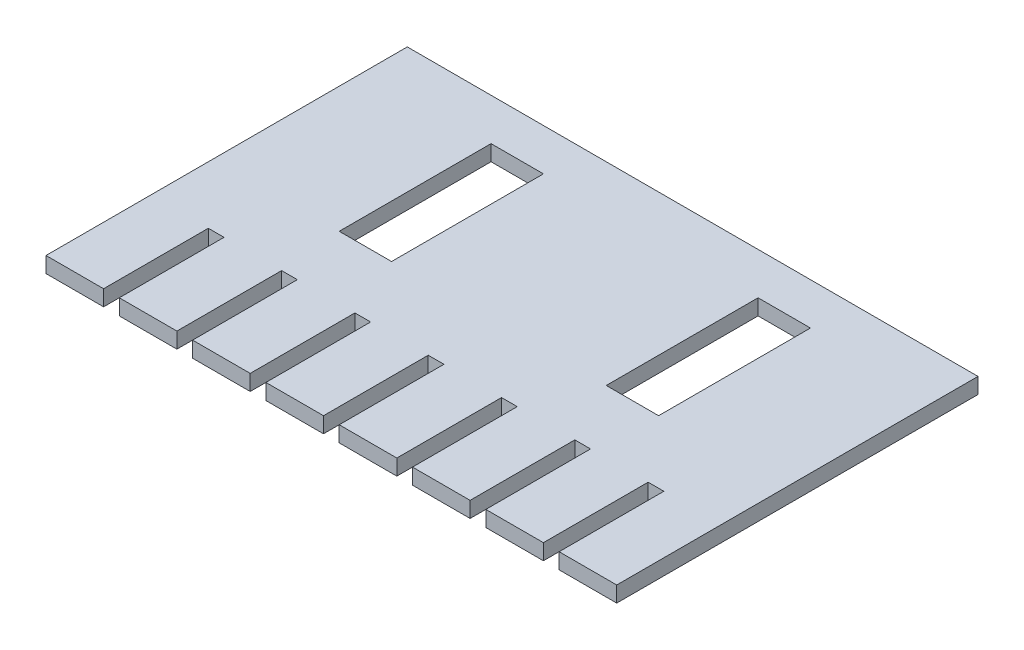
from build123d import *

# Parameters (mm, degrees)
SKETCH1_W           = 54.5
SKETCH1_H           = 34.5
BOSS_EXTRUDE1_DEPTH = 1.5
SKETCH6_W           = 5
SKETCH6_H           = 14.5
CUT_EXTRUDE1_DEPTH  = 2
SKETCH9_W           = 5
SKETCH9_H           = 14.5
CUT_EXTRUDE2_DEPTH  = 2
SKETCH27_W          = 1.5
SKETCH27_H          = 10
CUT_EXTRUDE3_DEPTH  = 2
SKETCH28_W          = 1.5
SKETCH28_H          = 10
CUT_EXTRUDE4_DEPTH  = 2
SKETCH29_W          = 1.5
SKETCH29_H          = 10
CUT_EXTRUDE5_DEPTH  = 2
SKETCH30_W          = 1.5
SKETCH30_H          = 10
CUT_EXTRUDE6_DEPTH  = 2
SKETCH31_W          = 1.5
SKETCH31_H          = 10
CUT_EXTRUDE7_DEPTH  = 2
SKETCH32_W          = 1.5
SKETCH32_H          = 10
CUT_EXTRUDE8_DEPTH  = 2
SKETCH33_W          = 1.5
SKETCH33_H          = 10
CUT_EXTRUDE9_DEPTH  = 2


with BuildPart() as part:
    # Sketch1 → Boss-Extrude1 (new body)
    with BuildSketch(Plane(origin=(0, 0, 0), x_dir=(1, 0, 0), z_dir=(0, 1, 0))):
        Rectangle(SKETCH1_W, SKETCH1_H)
    extrude(amount=BOSS_EXTRUDE1_DEPTH)

    # Sketch6 → Cut-Extrude1 (cut)
    with BuildSketch(Plane(origin=(0, 1.5, 0), x_dir=(1, 0, 0), z_dir=(0, 1, 0))):
        with Locations((-12.75, 6)):
            Rectangle(SKETCH6_W, SKETCH6_H)
    extrude(amount=-CUT_EXTRUDE1_DEPTH, mode=Mode.SUBTRACT)

    # Sketch9 → Cut-Extrude2 (cut)
    with BuildSketch(Plane(origin=(0, 1.5, 0), x_dir=(1, 0, 0), z_dir=(0, 1, 0))):
        with Locations((12.75, 6)):
            Rectangle(SKETCH9_W, SKETCH9_H)
    extrude(amount=-CUT_EXTRUDE2_DEPTH, mode=Mode.SUBTRACT)

    # Sketch27 → Cut-Extrude3 (cut)
    with BuildSketch(Plane(origin=(0, 1.5, 0), x_dir=(1, 0, 0), z_dir=(0, 1, 0))):
        with Locations((-21, -12.25)):
            Rectangle(SKETCH27_W, SKETCH27_H)
    extrude(amount=-CUT_EXTRUDE3_DEPTH, mode=Mode.SUBTRACT)

    # Sketch28 → Cut-Extrude4 (cut)
    with BuildSketch(Plane(origin=(0, 1.5, 0), x_dir=(1, 0, 0), z_dir=(0, 1, 0))):
        with Locations((-14, -12.25)):
            Rectangle(SKETCH28_W, SKETCH28_H)
    extrude(amount=-CUT_EXTRUDE4_DEPTH, mode=Mode.SUBTRACT)

    # Sketch29 → Cut-Extrude5 (cut)
    with BuildSketch(Plane(origin=(0, 1.5, 0), x_dir=(1, 0, 0), z_dir=(0, 1, 0))):
        with Locations((-7, -12.25)):
            Rectangle(SKETCH29_W, SKETCH29_H)
    extrude(amount=-CUT_EXTRUDE5_DEPTH, mode=Mode.SUBTRACT)

    # Sketch30 → Cut-Extrude6 (cut)
    with BuildSketch(Plane(origin=(0, 1.5, 0), x_dir=(1, 0, 0), z_dir=(0, 1, 0))):
        with Locations((0, -12.25)):
            Rectangle(SKETCH30_W, SKETCH30_H)
    extrude(amount=-CUT_EXTRUDE6_DEPTH, mode=Mode.SUBTRACT)

    # Sketch31 → Cut-Extrude7 (cut)
    with BuildSketch(Plane(origin=(0, 1.5, 0), x_dir=(1, 0, 0), z_dir=(0, 1, 0))):
        with Locations((7, -12.25)):
            Rectangle(SKETCH31_W, SKETCH31_H)
    extrude(amount=-CUT_EXTRUDE7_DEPTH, mode=Mode.SUBTRACT)

    # Sketch32 → Cut-Extrude8 (cut)
    with BuildSketch(Plane(origin=(0, 1.5, 0), x_dir=(1, 0, 0), z_dir=(0, 1, 0))):
        with Locations((14, -12.25)):
            Rectangle(SKETCH32_W, SKETCH32_H)
    extrude(amount=-CUT_EXTRUDE8_DEPTH, mode=Mode.SUBTRACT)

    # Sketch33 → Cut-Extrude9 (cut)
    with BuildSketch(Plane(origin=(0, 1.5, 0), x_dir=(1, 0, 0), z_dir=(0, 1, 0))):
        with Locations((21, -12.25)):
            Rectangle(SKETCH33_W, SKETCH33_H)
    extrude(amount=-CUT_EXTRUDE9_DEPTH, mode=Mode.SUBTRACT)


solid = part.part
